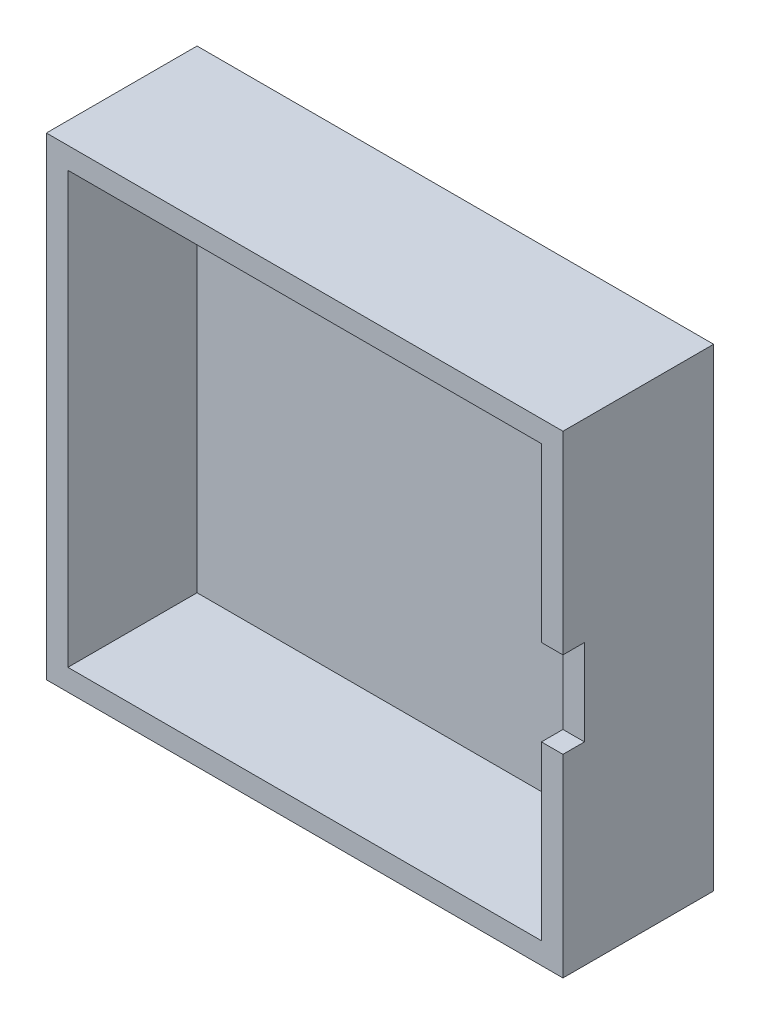
from build123d import *

# Parameters (mm, degrees)
ESQUISSE1_W              = 240
ESQUISSE1_H              = 220
ESQUISSE1_W_2            = 220
ESQUISSE1_H_2            = 200
BOSS_EXTRU_3_DEPTH       = 60
ESQUISSE1_2_W            = 240
ESQUISSE1_2_H            = 220
BOSS_EXTRU_4_DEPTH       = 10
ENL_V_MAT_EXTRU_17_DEPTH = 318.175030543


with BuildPart() as part:
    # Esquisse1 → Boss.-Extru.3 (new body)
    with BuildSketch(Plane.XY):
        with Locations((110, 100)):
            Rectangle(ESQUISSE1_W, ESQUISSE1_H)
        with Locations((110, 100)):
            Rectangle(ESQUISSE1_W_2, ESQUISSE1_H_2, mode=Mode.SUBTRACT)
    extrude(amount=BOSS_EXTRU_3_DEPTH)

    # Esquisse1_2 → Boss.-Extru.4 (add)
    with BuildSketch(Plane.XY):
        with Locations((110, 100)):
            Rectangle(ESQUISSE1_2_W, ESQUISSE1_2_H)
    extrude(amount=-BOSS_EXTRU_4_DEPTH)

    # Esquisse4 → Enlèv. mat.-Extru.17 (cut, through all)
    with BuildSketch(Plane.ZY.offset(-220)):
        Polygon((365.296461205, 120), (60, 120), (50, 120), (50, 80), (60, 80), (365.296461205, 80), (975.889383614, 80), (975.889383614, 120), align=None)
    extrude(amount=-ENL_V_MAT_EXTRU_17_DEPTH, mode=Mode.SUBTRACT)


solid = part.part
